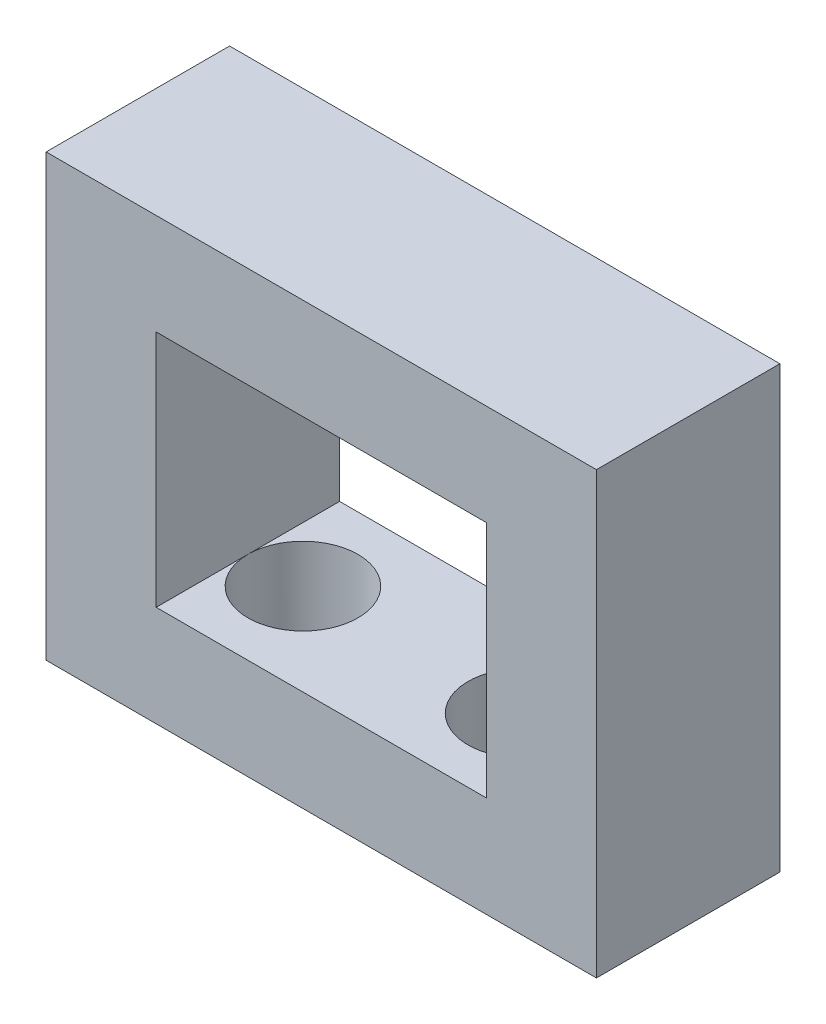
from build123d import *

# Parameters (mm, degrees)
SKETCH_1_W          = 15
SKETCH_1_H          = 12
EXTRUDE_1_DEPTH     = 2.5
SKETCH_2_W          = 9
SKETCH_2_H          = 6.5
CUT_EXTRUDE_1_DEPTH = 6
CUT_EXTRUDE_2_REACH = 14
SKETCH_3_R          = 1.5


with BuildPart() as part:
    # 草圖1 → 填料-伸長1 (new body, symmetric)
    with BuildSketch(Plane.XY):
        Rectangle(SKETCH_1_W, SKETCH_1_H)
    extrude(amount=EXTRUDE_1_DEPTH, both=True)

    # 草圖2 → 除料-伸長1 (cut, through all)
    with BuildSketch(Plane.XY.offset(2.5)):
        Rectangle(SKETCH_2_W, SKETCH_2_H)
    extrude(amount=-CUT_EXTRUDE_1_DEPTH, mode=Mode.SUBTRACT)

    # 草圖3 → 除料-伸長2 (cut, up to next)
    with BuildSketch(Plane.XZ.offset(6), mode=Mode.PRIVATE) as cut_extrude_2_sk1:
        with Locations((-3, 0)):
            Circle(SKETCH_3_R)
    cut_extrude_2_tool1 = extrude(cut_extrude_2_sk1.sketch, amount=-CUT_EXTRUDE_2_REACH, mode=Mode.PRIVATE) & part.part
    add(cut_extrude_2_tool1.solids().sort_by_distance((-3, -6, 0))[0], mode=Mode.SUBTRACT)
    # 草圖3 → 除料-伸長2 (cut, up to next)
    with BuildSketch(Plane.XZ.offset(6), mode=Mode.PRIVATE) as cut_extrude_2_sk2:
        with Locations((3, 0)):
            Circle(SKETCH_3_R)
    cut_extrude_2_tool2 = extrude(cut_extrude_2_sk2.sketch, amount=-CUT_EXTRUDE_2_REACH, mode=Mode.PRIVATE) & part.part
    add(cut_extrude_2_tool2.solids().sort_by_distance((3, -6, 0))[0], mode=Mode.SUBTRACT)


solid = part.part
